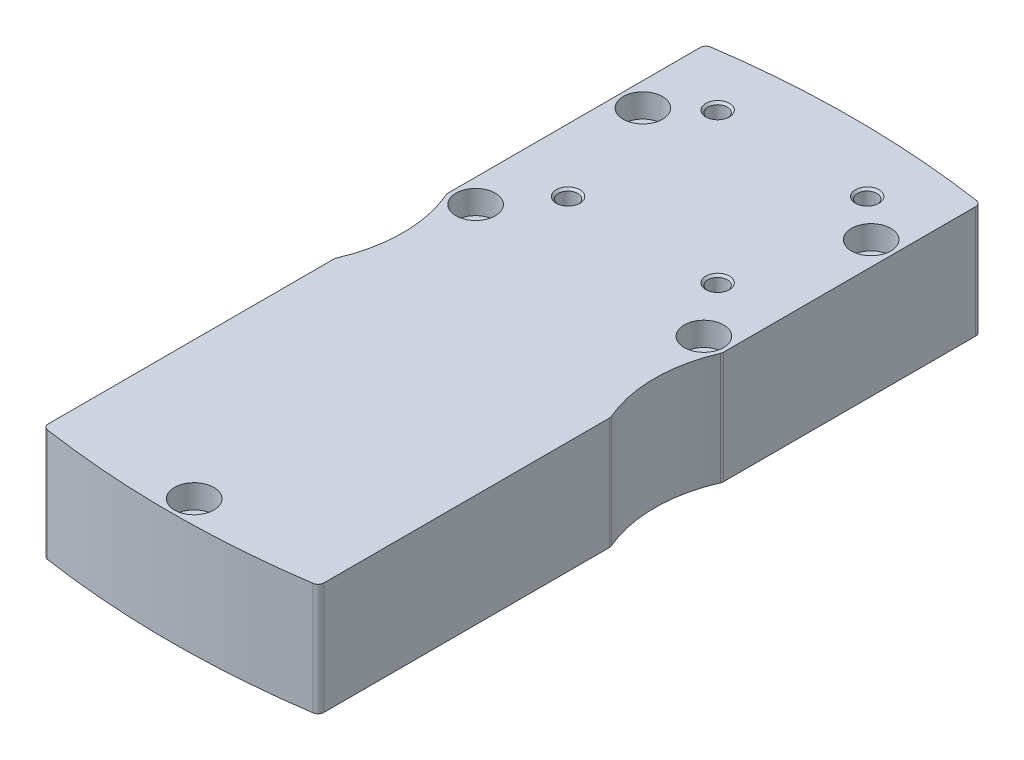
from build123d import *

# Parameters (mm, degrees)
BOSS_EXTRUDE1_DEPTH = 28.5
CUT_EXTRUDE1_DEPTH  = 26.5
CUT_EXTRUDE2_DEPTH  = 8
CUT_EXTRUDE3_DEPTH  = 3


with BuildPart() as part:
    # Sketch1 → Boss-Extrude1 (new body)
    with BuildSketch(Plane(origin=(0, 0, 0), x_dir=(1, 0, 0), z_dir=(0, 1, 0))):
        with BuildLine():
            Line((-35, 76.508623254), (-35, 3.969028671))
            ThreePointArc((-35, 3.969028671), (-34.63575277, 2.989199275), (-33.719912473, 2.485236737))
            ThreePointArc((-33.719912473, 2.485236737), (0, 0), (33.719912473, 2.485236737))
            ThreePointArc((33.719912473, 2.485236737), (34.63575277, 2.989199275), (35, 3.969028671))
            Line((35, 3.969028671), (35, 76.508623254))
            ThreePointArc((35, 76.508623254), (34.96885474, 76.812705074), (34.876712329, 77.104159284))
            ThreePointArc((34.876712329, 77.104159284), (32, 91), (34.876712329, 104.895840716))
            ThreePointArc((34.876712329, 104.895840716), (34.96885474, 105.187294926), (35, 105.491376746))
            Line((35, 105.491376746), (35, 169.530971329))
            ThreePointArc((35, 169.530971329), (34.63575277, 170.510800725), (33.719912473, 171.014763263))
            ThreePointArc((33.719912473, 171.014763263), (0, 173.5), (-33.719912473, 171.014763263))
            ThreePointArc((-33.719912473, 171.014763263), (-34.63575277, 170.510800725), (-35, 169.530971329))
            Line((-35, 169.530971329), (-35, 105.491376746))
            ThreePointArc((-35, 105.491376746), (-34.96885474, 105.187294926), (-34.876712329, 104.895840716))
            ThreePointArc((-34.876712329, 104.895840716), (-32, 91), (-34.876712329, 77.104159284))
            ThreePointArc((-34.876712329, 77.104159284), (-34.96885474, 76.812705074), (-35, 76.508623254))
        make_face()
    extrude(amount=BOSS_EXTRUDE1_DEPTH)

    # Sketch2 → Cut-Extrude1 (cut)
    with BuildSketch(Plane(origin=(0, 0, 0), x_dir=(1, 0, 0), z_dir=(0, 1, 0))):
        with BuildLine():
            Line((20, 55.5), (20, 106.320508076))
            ThreePointArc((20, 106.320508076), (19.659258263, 108.908698527), (18.660254038, 111.320508076))
            Line((18.660254038, 111.320508076), (13.339745962, 120.535898385))
            ThreePointArc((13.339745962, 120.535898385), (12.340741737, 122.947707934), (12, 125.535898385))
            Line((12, 125.535898385), (12, 147))
            ThreePointArc((12, 147), (0, 159), (-12, 147))
            Line((-12, 147), (-12, 125.535898385))
            ThreePointArc((-12, 125.535898385), (-12.340741737, 122.947707934), (-13.339745962, 120.535898385))
            Line((-13.339745962, 120.535898385), (-18.660254038, 111.320508076))
            ThreePointArc((-18.660254038, 111.320508076), (-19.659258263, 108.908698527), (-20, 106.320508076))
            Line((-20, 106.320508076), (-20, 55.5))
            ThreePointArc((-20, 55.5), (-20.194193243, 53.538838649), (-20.769230769, 51.653846154))
            ThreePointArc((-20.769230769, 51.653846154), (0, 20.5), (20.769230769, 51.653846154))
            ThreePointArc((20.769230769, 51.653846154), (20.194193243, 53.538838649), (20, 55.5))
        make_face()
    extrude(amount=CUT_EXTRUDE1_DEPTH, mode=Mode.SUBTRACT)

    # Sketch3 → Cut-Extrude2 (cut)
    with BuildSketch(Plane(origin=(0, 0, 0), x_dir=(1, 0, 0), z_dir=(0, 1, 0))):
        with BuildLine():
            ThreePointArc((-7.988063039, 156.239224138), (0, 120), (7.988063039, 156.239224138))
            ThreePointArc((7.988063039, 156.239224138), (7.304821226, 156.588253024), (6.650349133, 156.988636364))
            ThreePointArc((6.650349133, 156.988636364), (0, 159), (-6.650349133, 156.988636364))
            ThreePointArc((-6.650349133, 156.988636364), (-7.304821226, 156.588253024), (-7.988063039, 156.239224138))
        make_face()
    extrude(amount=CUT_EXTRUDE2_DEPTH, mode=Mode.SUBTRACT)

    # Sketch4 → Cut-Extrude3 (cut)
    with BuildSketch(Plane(origin=(0, 0, 0), x_dir=(1, 0, 0), z_dir=(0, 1, 0))):
        with BuildLine():
            Line((25, 51.426149773), (25, 130.573850227))
            ThreePointArc((25, 130.573850227), (25.06968726, 131.752361529), (25.277777778, 132.914447386))
            ThreePointArc((25.277777778, 132.914447386), (0, 165), (-25.277777778, 132.914447386))
            ThreePointArc((-25.277777778, 132.914447386), (-25.06968726, 131.752361529), (-25, 130.573850227))
            Line((-25, 130.573850227), (-25, 51.426149773))
            ThreePointArc((-25, 51.426149773), (-25.06968726, 50.247638471), (-25.277777778, 49.085552614))
            ThreePointArc((-25.277777778, 49.085552614), (0, 17), (25.277777778, 49.085552614))
            ThreePointArc((25.277777778, 49.085552614), (25.06968726, 50.247638471), (25, 51.426149773))
        make_face()
    extrude(amount=CUT_EXTRUDE3_DEPTH, mode=Mode.SUBTRACT)

    # Sketch5 → Cut-Revolve1 (revolve, cut)
    with BuildSketch(Plane(origin=(0, 0, 0), x_dir=(0, 0, -1), z_dir=(1, 0, 0))):
        Polygon((6, 28.5), (11, 28.5), (11, 22.5), (8.75, 22.5), (8.75, 0), (6, 0), align=None)
    revolve(axis=Axis((0, 0, -6), (0, 1, 0)), mode=Mode.SUBTRACT)

    # Sketch6 → Cut-Revolve2 (revolve, cut)
    with BuildSketch(Plane(origin=(29, 0, 0), x_dir=(0, 0, -1), z_dir=(1, 0, 0))):
        Polygon((106.5, 28.5), (111.5, 28.5), (111.5, 22.5), (109.25, 22.5), (109.25, 0), (106.5, 0), align=None)
    revolve(axis=Axis((29, 0, -106.5), (0, 1, 0)), mode=Mode.SUBTRACT)

    # Sketch7 → Cut-Revolve3 (revolve, cut)
    with BuildSketch(Plane(origin=(29, 0, 0), x_dir=(0, 0, -1), z_dir=(1, 0, 0))):
        Polygon((149, 28.5), (154, 28.5), (154, 22.5), (151.75, 22.5), (151.75, 0), (149, 0), align=None)
    revolve(axis=Axis((29, 0, -149), (0, 1, 0)), mode=Mode.SUBTRACT)

    # Sketch8 → Cut-Revolve4 (revolve, cut)
    with BuildSketch(Plane(origin=(-29, 0, 0), x_dir=(0, 0, -1), z_dir=(1, 0, 0))):
        Polygon((106.5, 28.5), (111.5, 28.5), (111.5, 22.5), (109.25, 22.5), (109.25, 0), (106.5, 0), align=None)
    revolve(axis=Axis((-29, 0, -106.5), (0, 1, 0)), mode=Mode.SUBTRACT)

    # Sketch9 → Cut-Revolve5 (revolve, cut)
    with BuildSketch(Plane(origin=(-29, 0, 0), x_dir=(0, 0, -1), z_dir=(1, 0, 0))):
        Polygon((149, 28.5), (154, 28.5), (154, 22.5), (151.75, 22.5), (151.75, 0), (149, 0), align=None)
    revolve(axis=Axis((-29, 0, -149), (0, 1, 0)), mode=Mode.SUBTRACT)

    # Sketch10 → Cut-Revolve6 (revolve, cut)
    with BuildSketch(Plane.XY.offset(-158)):
        Polygon((19, 28.5), (22, 28.5), (21.4585, 27.9585), (21.4585, 12), (19, 10.580584363), align=None)
    revolve(axis=Axis((19, 10.580584363, -158), (0, 1, 0)), mode=Mode.SUBTRACT)

    # Sketch11 → Cut-Revolve7 (revolve, cut)
    with BuildSketch(Plane.XY.offset(-158)):
        Polygon((-19, 28.5), (-16, 28.5), (-16.5415, 27.9585), (-16.5415, 12), (-19, 10.580584363), align=None)
    revolve(axis=Axis((-19, 10.580584363, -158), (0, 1, 0)), mode=Mode.SUBTRACT)

    # Sketch12 → Cut-Revolve8 (revolve, cut)
    with BuildSketch(Plane.XY.offset(-120)):
        Polygon((19, 28.5), (22, 28.5), (21.4585, 27.9585), (21.4585, 12), (19, 10.580584363), align=None)
    revolve(axis=Axis((19, 10.580584363, -120), (0, 1, 0)), mode=Mode.SUBTRACT)

    # Sketch13 → Cut-Revolve9 (revolve, cut)
    with BuildSketch(Plane.XY.offset(-120)):
        Polygon((-19, 28.5), (-16, 28.5), (-16.5415, 27.9585), (-16.5415, 12), (-19, 10.580584363), align=None)
    revolve(axis=Axis((-19, 10.580584363, -120), (0, 1, 0)), mode=Mode.SUBTRACT)


solid = part.part
